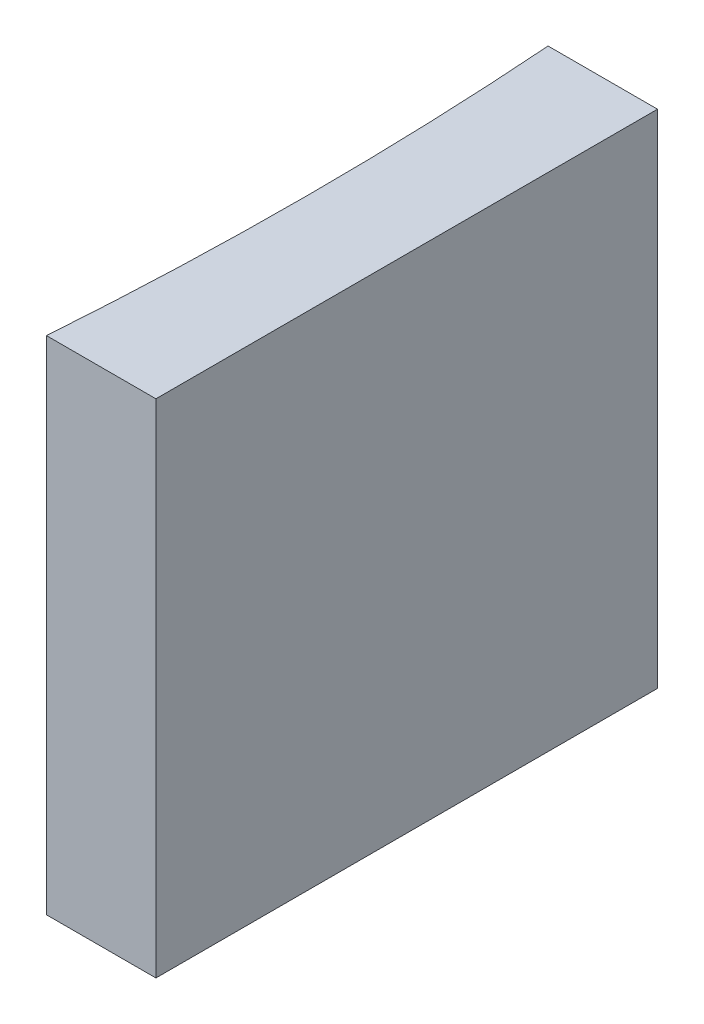
from build123d import *

# Parameters (mm, degrees)
EXTRUDE_1_DEPTH = 10


with BuildPart() as part:
    # 草图1 → 凸台-拉伸1 (new body)
    with BuildSketch(Plane(origin=(0, 0, 0), x_dir=(1, 0, 0), z_dir=(0, 1, 0))):
        with BuildLine():
            Line((0, 0), (0, -10))
            Line((0, -10), (-2.18197962, -10))
            ThreePointArc((-2.18197962, -10), (-2, -5), (-2.18197962, 0))
            Line((-2.18197962, 0), (0, 0))
        make_face()
    extrude(amount=EXTRUDE_1_DEPTH)


solid = part.part
